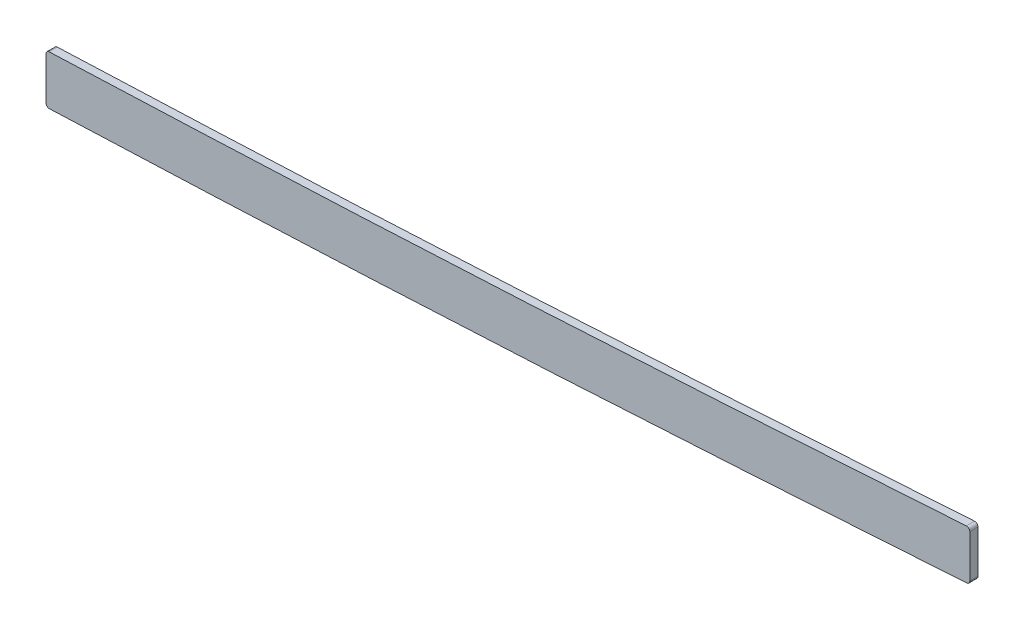
from build123d import *

# Parameters (mm, degrees)
BOSS_EXTRUDE1_DEPTH = 1.5875
FILLET1_R           = 1.27


with BuildPart() as part:
    # Sketch1 → Boss-Extrude1 (new body, symmetric)
    with BuildSketch(Plane.XY):
        with BuildLine():
            Line((2311.4, -9.245652974), (2311.4, -28.310356345))
            add(Edge.make_bspline(
                [(2669.54, -9.569049356), (2615.393603553, -13.17073937), (2561.080658619, -16.536108081), (2506.205230446, -19.758621957), (2434.382223772, -23.29947809), (2362.559217098, -26.286274493), (2345.393069943, -26.972929947), (2328.342945407, -27.644579597), (2311.4, -28.310356345)],
                knots=[103.698913506, 103.698913506, 103.698913506, 103.698913506, 103.698913506, 103.698913506, 130.927896619, 130.927896619, 130.927896619, 139.270260279, 139.270260279, 139.270260279, 139.270260279, 139.270260279, 139.270260279], degree=5))
            Line((2669.54, -9.569049356), (2669.54, 9.5231025))
            add(Edge.make_bspline(
                [(2669.54, 9.5231025), (2667.126494524, 9.36235515), (2659.861586685, 8.880281494), (2635.666282302, 7.292469146), (2596.857665529, 4.826056853), (2545.729743039, 1.758344093), (2494.405305707, -1.098555235), (2451.533022267, -3.266573297), (2417.198316756, -4.86708361), (2391.457076919, -6.003589235), (2365.634736307, -7.086854581), (2341.015642019, -8.078542398), (2322.924133841, -8.79260451), (2313.562932275, -9.160652062), (2311.4, -9.245652974)],
                knots=[103.571582669, 103.571582669, 103.571582669, 103.571582669, 104.300777207, 105.766098403, 110.877392287, 115.98868617, 121.099980054, 126.211273938, 128.76692088, 131.322567822, 133.878214764, 136.433861706, 138.557690156, 139.196601892, 139.196601892, 139.196601892, 139.196601892], degree=3))
        make_face()
    extrude(amount=BOSS_EXTRUDE1_DEPTH, both=True)

    # Fillet1
    fillet1_edges = [part.edges().sort_by_distance(p)[0] for p in [
        (2669.54, 9.5231025, -0.79375),
        (2669.54, -9.569049356, -0.79375),
        (2311.4, -9.245652974, -0.79375),
        (2311.4, -28.310356345, -0.79375),
    ]]
    fillet(fillet1_edges, radius=FILLET1_R)


solid = part.part
